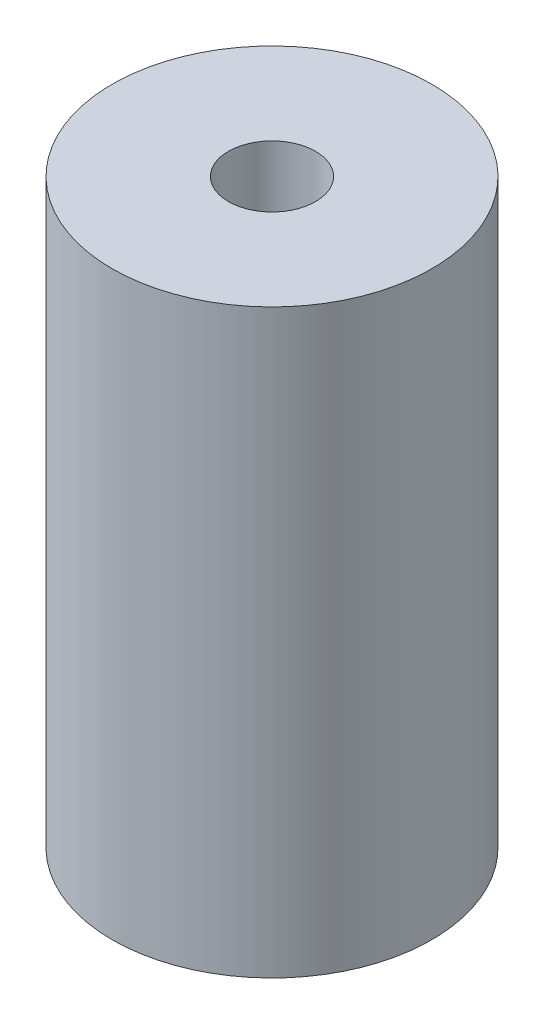
from build123d import *

# Parameters (mm, degrees)
SKETCH1_R           = 5.5
SKETCH1_R_2         = 1.5
BOSS_EXTRUDE1_DEPTH = 20


with BuildPart() as part:
    # Sketch1 → Boss-Extrude1 (new body)
    with BuildSketch(Plane(origin=(0, 0, 0), x_dir=(1, 0, 0), z_dir=(0, 1, 0))):
        Circle(SKETCH1_R)
        Circle(SKETCH1_R_2, mode=Mode.SUBTRACT)
    extrude(amount=BOSS_EXTRUDE1_DEPTH)


solid = part.part
